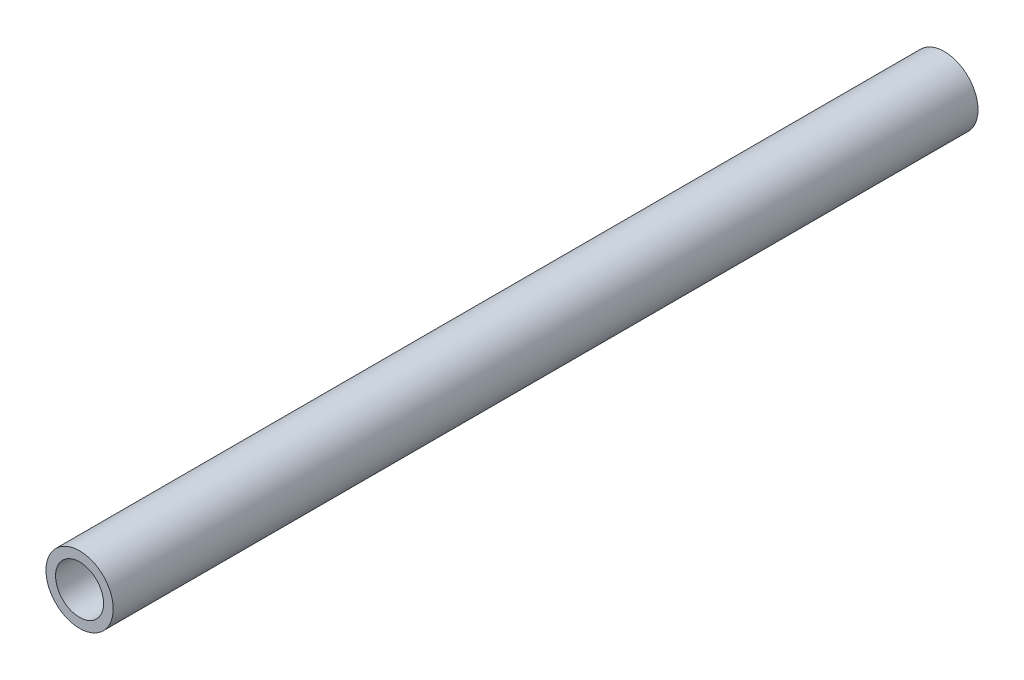
from build123d import *

# Parameters (mm, degrees)
SKETCH1_R           = 3.5
SKETCH1_R_2         = 2.5
BOSS_EXTRUDE1_DEPTH = 90


with BuildPart() as part:
    # Sketch1 → Boss-Extrude1 (new body)
    with BuildSketch(Plane.XY):
        Circle(SKETCH1_R)
        Circle(SKETCH1_R_2, mode=Mode.SUBTRACT)
    extrude(amount=BOSS_EXTRUDE1_DEPTH)


solid = part.part
